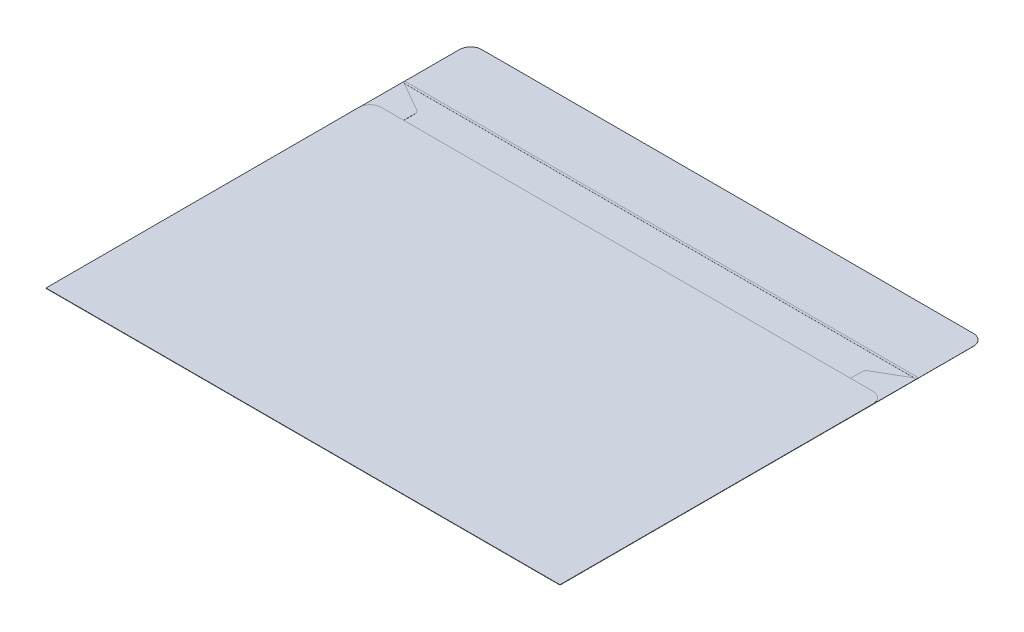
from build123d import *

# Parameters (mm, degrees)
BOSS_EXTRUDE1_DEPTH      = 0.05
SKETCH2_W                = 230
SKETCH2_H                = 145
BOSS_EXTRUDE2_DEPTH      = 0.1
BOSS_EXTRUDE3_DEPTH      = 0.05
BOSS_EXTRUDE7_DEPTH      = 0.03
BOSS_EXTRUDE7_DEPTH_BACK = 0.08
SKETCH3_W                = 230
SKETCH3_H                = 1
FILLET1_R                = 5
FILLET2_R                = 2


with BuildPart() as part:
    # Sketch1 → Boss-Extrude1 (new body)
    with BuildSketch(Plane(origin=(0, 0, 0), x_dir=(1, 0, 0), z_dir=(0, 1, 0))):
        with BuildLine():
            Line((-115, 80), (-115, -80))
            Line((-115, -80), (115, -80))
            Line((115, -80), (115, 80))
            Line((115, 80), (115, 105))
            ThreePointArc((115, 105), (113.535533906, 108.535533906), (110, 110))
            Line((110, 110), (-110, 110))
            ThreePointArc((-110, 110), (-113.535533906, 108.535533906), (-115, 105))
            Line((-115, 105), (-115, 80))
        make_face()
    extrude(amount=BOSS_EXTRUDE1_DEPTH)

    # Sketch2 → Boss-Extrude2 (add)
    with BuildSketch(Plane(origin=(0, 0.05, 0), x_dir=(1, 0, 0), z_dir=(0, 1, 0))):
        with Locations((0, -7.5)):
            Rectangle(SKETCH2_W, SKETCH2_H)
    extrude(amount=BOSS_EXTRUDE2_DEPTH)

    # Sketch2_3 → Boss-Extrude3 (add)
    with BuildSketch(Plane(origin=(0, 0.05, 0), x_dir=(1, 0, 0), z_dir=(0, 1, 0))):
        Polygon((-115, 80), (-115, 65), (-100, 65), (-100, 71.339745962), align=None)
        Polygon((100, 71.339745962), (100, 65), (115, 65), (115, 80), align=None)
    extrude(amount=BOSS_EXTRUDE3_DEPTH)

    # Sketch3 → Boss-Extrude7 (add, two sides: drawn at the far end of the back side and taken through both)
    with BuildSketch(Plane(origin=(0, 0.05, 0), x_dir=(1, 0, 0), z_dir=(0, 1, 0)).offset(-BOSS_EXTRUDE7_DEPTH_BACK)):
        with Locations((0, 80)):
            Rectangle(SKETCH3_W, SKETCH3_H)
    extrude(amount=BOSS_EXTRUDE7_DEPTH + BOSS_EXTRUDE7_DEPTH_BACK)

    # Fillet1
    fillet1_edges = [part.edges().sort_by_distance(p)[0] for p in [
        (115, 0.125, -65),
        (-115, 0.125, -65),
    ]]
    fillet(fillet1_edges, radius=FILLET1_R)

    # Fillet2
    fillet2_edges = [part.edges().sort_by_distance(p)[0] for p in [
        (100, 0.075, -71.339745962),
        (-100, 0.075, -71.339745962),
    ]]
    fillet(fillet2_edges, radius=FILLET2_R)


solid = part.part
